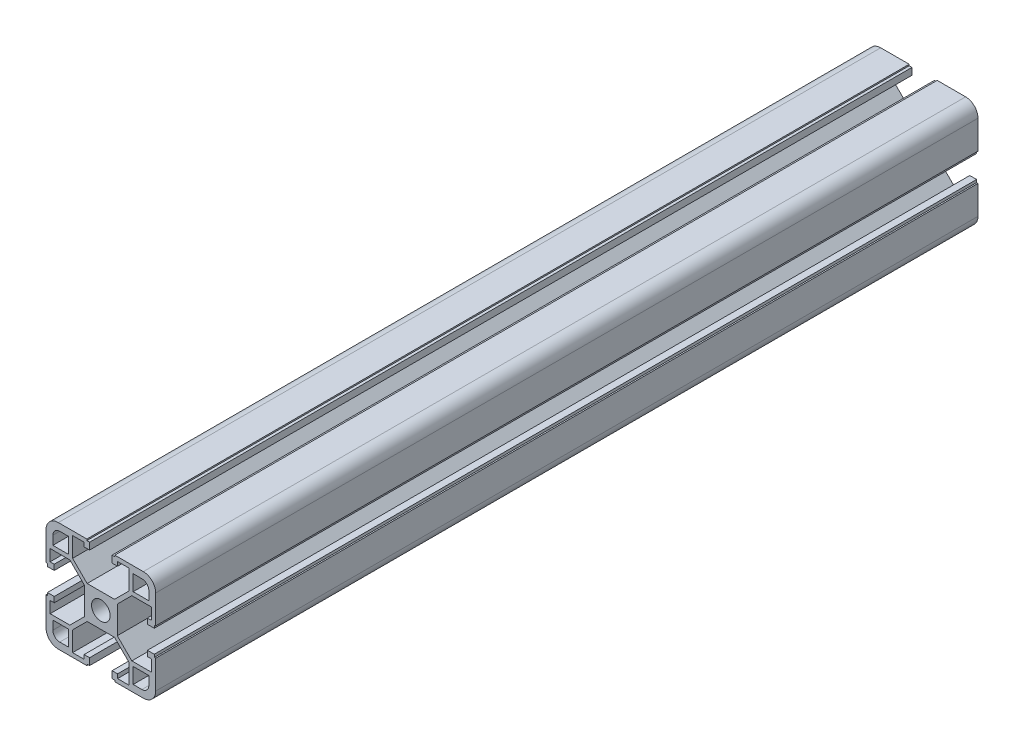
from build123d import *

# Parameters (mm, degrees)
SKETCH1_R                 = 3.4
F_40_X_40L_X_R4_5_1_DEPTH = 300


with BuildPart() as part:
    # Sketch1 → 铝型材 40 X 40L X R4.5(1) (new body)
    with BuildSketch(Plane.XY.offset(-151.807228916)):
        with BuildLine():
            Line((-5.1, 20), (-5.1, 19.5))
            Line((-5.1, 19.5), (-4.1, 19.5))
            Line((-4.1, 19.5), (-4.1, 17))
            Line((-4.1, 17), (-6.1, 17))
            Line((-6.1, 17), (-6.1, 18.5))
            Line((-6.1, 18.5), (-10.3, 18.5))
            Line((-10.3, 18.5), (-10.3, 11.3))
            Line((-10.3, 11.3), (-5, 6))
            Line((-5, 6), (5, 6))
            Line((5, 6), (10.3, 11.3))
            Line((10.3, 11.3), (10.3, 18.5))
            Line((10.3, 18.5), (6.1, 18.5))
            Line((6.1, 18.5), (6.1, 17))
            Line((6.1, 17), (4.1, 17))
            Line((4.1, 17), (4.1, 19.5))
            Line((4.1, 19.5), (5.1, 19.5))
            Line((5.1, 19.5), (5.1, 20))
            Line((5.1, 20), (15.5, 20))
            ThreePointArc((15.5, 20), (18.681980515, 18.681980515), (20, 15.5))
            Line((20, 15.5), (20, 5.1))
            Line((20, 5.1), (19.5, 5.1))
            Line((19.5, 5.1), (19.5, 4.1))
            Line((19.5, 4.1), (17, 4.1))
            Line((17, 4.1), (17, 6.1))
            Line((17, 6.1), (18.5, 6.1))
            Line((18.5, 6.1), (18.5, 10.3))
            Line((18.5, 10.3), (11.3, 10.3))
            Line((11.3, 10.3), (6, 5))
            Line((6, 5), (6, -5))
            Line((6, -5), (11.3, -10.3))
            Line((11.3, -10.3), (18.5, -10.3))
            Line((18.5, -10.3), (18.5, -6.1))
            Line((18.5, -6.1), (17, -6.1))
            Line((17, -6.1), (17, -4.1))
            Line((17, -4.1), (19.5, -4.1))
            Line((19.5, -4.1), (19.5, -5.1))
            Line((19.5, -5.1), (20, -5.1))
            Line((20, -5.1), (20, -15.5))
            ThreePointArc((20, -15.5), (18.681980515, -18.681980515), (15.5, -20))
            Line((15.5, -20), (5.1, -20))
            Line((5.1, -20), (5.1, -19.5))
            Line((5.1, -19.5), (4.1, -19.5))
            Line((4.1, -19.5), (4.1, -17))
            Line((4.1, -17), (6.1, -17))
            Line((6.1, -17), (6.1, -18.5))
            Line((6.1, -18.5), (10.3, -18.5))
            Line((10.3, -18.5), (10.3, -11.3))
            Line((10.3, -11.3), (5, -6))
            Line((5, -6), (-5, -6))
            Line((-5, -6), (-10.3, -11.3))
            Line((-10.3, -11.3), (-10.3, -18.5))
            Line((-10.3, -18.5), (-6.1, -18.5))
            Line((-6.1, -18.5), (-6.1, -17))
            Line((-6.1, -17), (-4.1, -17))
            Line((-4.1, -17), (-4.1, -19.5))
            Line((-4.1, -19.5), (-5.1, -19.5))
            Line((-5.1, -19.5), (-5.1, -20))
            Line((-5.1, -20), (-15.5, -20))
            ThreePointArc((-15.5, -20), (-18.681980515, -18.681980515), (-20, -15.5))
            Line((-20, -15.5), (-20, -5.1))
            Line((-20, -5.1), (-19.5, -5.1))
            Line((-19.5, -5.1), (-19.5, -4.1))
            Line((-19.5, -4.1), (-17, -4.1))
            Line((-17, -4.1), (-17, -6.1))
            Line((-17, -6.1), (-18.5, -6.1))
            Line((-18.5, -6.1), (-18.5, -10.3))
            Line((-18.5, -10.3), (-11.3, -10.3))
            Line((-11.3, -10.3), (-6, -5))
            Line((-6, -5), (-6, 5))
            Line((-6, 5), (-11.3, 10.3))
            Line((-11.3, 10.3), (-18.5, 10.3))
            Line((-18.5, 10.3), (-18.5, 6.1))
            Line((-18.5, 6.1), (-17, 6.1))
            Line((-17, 6.1), (-17, 4.1))
            Line((-17, 4.1), (-19.5, 4.1))
            Line((-19.5, 4.1), (-19.5, 5.1))
            Line((-19.5, 5.1), (-20, 5.1))
            Line((-20, 5.1), (-20, 15.5))
            ThreePointArc((-20, 15.5), (-18.681980515, 18.681980515), (-15.5, 20))
            Line((-15.5, 20), (-5.1, 20))
        make_face()
        Circle(SKETCH1_R, mode=Mode.SUBTRACT)
        with BuildLine():
            Line((11.8, 17.5), (15, 17.5))
            ThreePointArc((15, 17.5), (16.767766953, 16.767766953), (17.5, 15))
            Line((17.5, 15), (17.5, 11.8))
            Line((17.5, 11.8), (11.8, 11.8))
            Line((11.8, 11.8), (11.8, 17.5))
        make_face(mode=Mode.SUBTRACT)
        with BuildLine():
            Line((-15, 17.5), (-11.8, 17.5))
            Line((-11.8, 17.5), (-11.8, 11.8))
            Line((-11.8, 11.8), (-17.5, 11.8))
            Line((-17.5, 11.8), (-17.5, 15))
            ThreePointArc((-17.5, 15), (-16.767766953, 16.767766953), (-15, 17.5))
        make_face(mode=Mode.SUBTRACT)
        with BuildLine():
            Line((-17.5, -11.8), (-11.8, -11.8))
            Line((-11.8, -11.8), (-11.8, -17.5))
            Line((-11.8, -17.5), (-15, -17.5))
            ThreePointArc((-15, -17.5), (-16.767766953, -16.767766953), (-17.5, -15))
            Line((-17.5, -15), (-17.5, -11.8))
        make_face(mode=Mode.SUBTRACT)
        with BuildLine():
            Line((11.8, -11.8), (17.5, -11.8))
            Line((17.5, -11.8), (17.5, -15))
            ThreePointArc((17.5, -15), (16.767766953, -16.767766953), (15, -17.5))
            Line((15, -17.5), (11.8, -17.5))
            Line((11.8, -17.5), (11.8, -11.8))
        make_face(mode=Mode.SUBTRACT)
    extrude(amount=F_40_X_40L_X_R4_5_1_DEPTH)


solid = part.part
